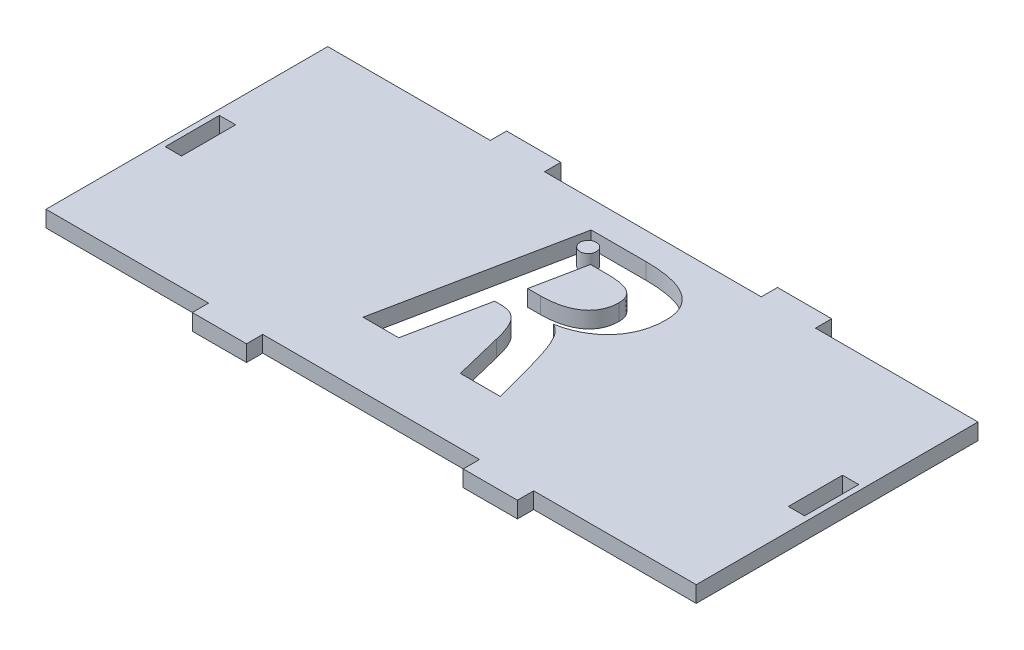
from build123d import *

# Parameters (mm, degrees)
SKETCH1_W             = 10
SKETCH1_H             = 3
BOSS_EXTRUDE1_DEPTH   = 3
BODY_MOVE_COPY1_ANGLE = 90
CUT_EXTRUDE1_DEPTH    = 10
SKETCH5_R             = 1.5
BOSS_EXTRUDE2_DEPTH   = 3


with BuildPart() as part:
    # Sketch1 → Boss-Extrude1 (new body)
    with BuildSketch(Plane(origin=(0, 0, 0), x_dir=(1, 0, 0), z_dir=(0, 1, 0))):
        Polygon((-26, 60), (26, 60), (26, 30), (29, 30), (29, 20), (26, 20), (26, -20), (29, -20), (29, -30), (26, -30), (26, -60), (-26, -60), (-26, -30), (-29, -30), (-29, -20), (-26, -20), (-26, 20), (-29, 20), (-29, 30), (-26, 30), align=None)
        with Locations((0, 57.5)):
            Rectangle(SKETCH1_W, SKETCH1_H, mode=Mode.SUBTRACT)
        with Locations((0, -57.5)):
            Rectangle(SKETCH1_W, SKETCH1_H, mode=Mode.SUBTRACT)
    extrude(amount=BOSS_EXTRUDE1_DEPTH)


with BuildPart() as part_1:
    # Body-Move/Copy1: moved
    add(part.part.rotate(Axis((2.335824912, 0, 2.335824912), (0, 1, 0)), BODY_MOVE_COPY1_ANGLE))

    # Sketch3 → Cut-Extrude1 (cut)
    with BuildSketch(Plane(origin=(0, 3, 0), x_dir=(1, 0, 0), z_dir=(0, 1, 0))):
        with BuildLine():
            Line((4.466938406, -18.671649823), (2.30321558, -9.810689678))
            add(Edge.make_bspline(
                [(2.30321558, -9.810689678), (2.237575072, -9.527203361), (2.112322927, -8.986268034), (1.884560825, -8.221822452), (1.661058011, -7.531047935), (1.413133081, -6.918626032), (1.157295895, -6.373259853), (0.894743907, -5.8869704), (0.595714484, -5.47180495), (0.194869077, -5.00534387), (-0.35624983, -4.53279488), (-1.130467052, -4.171954214), (-1.987113549, -3.997311886), (-2.583582774, -3.973814602), (-2.896059783, -3.961504895)],
                knots=[0, 0, 0, 0, 0.00087273, 0.001665302, 0.002392139, 0.003050022, 0.003645666, 0.004199163, 0.004704983, 0.005176946, 0.006043573, 0.006858998, 0.007710931, 0.008648313, 0.008648313, 0.008648313, 0.008648313], degree=3))
            Line((-2.896059783, -3.961504895), (-3.918478261, -3.961504895))
            Line((-3.918478261, -3.961504895), (-6.914402174, -18.671649823))
            Line((-6.914402174, -18.671649823), (-13.492753623, -18.671649823))
            Line((-13.492753623, -18.671649823), (-6.391304348, 16.328350177))
            Line((-6.391304348, 16.328350177), (3.769474638, 16.328350177))
            add(Edge.make_bspline(
                [(3.769474638, 16.328350177), (4.179114658, 16.324666316), (4.983349625, 16.317433894), (6.157480568, 16.235094411), (7.276899975, 16.110679294), (8.333759624, 15.931675368), (9.326691627, 15.693744473), (10.253459532, 15.406039359), (11.100069006, 15.038863675), (11.876823255, 14.621025917), (12.570210089, 14.133703622), (13.189907339, 13.589154481), (13.705367007, 12.959487705), (14.149571746, 12.275556031), (14.492611839, 11.511094404), (14.736787252, 10.668501563), (14.889995303, 9.747634617), (14.905202054, 9.105997443), (14.913043478, 8.775134597)],
                knots=[0, 0, 0, 0, 0.001228717, 0.002412307, 0.003529131, 0.004606709, 0.005625558, 0.006590578, 0.007513678, 0.008389749, 0.009231892, 0.010051352, 0.010856077, 0.011665161, 0.012491643, 0.013359356, 0.014290991, 0.015282848, 0.015282848, 0.015282848, 0.015282848], degree=3))
            add(Edge.make_bspline(
                [(14.913043478, 8.775134597), (14.90634048, 8.431261664), (14.893093398, 7.751668308), (14.760533036, 6.752319412), (14.555714135, 5.783564983), (14.26379236, 4.851946617), (13.888546868, 3.962405889), (13.443769752, 3.112441971), (12.911937837, 2.31580861), (12.30828054, 1.56624831), (11.631026441, 0.880423971), (10.901354362, 0.237517458), (10.094211296, -0.329736345), (9.23357218, -0.847429864), (8.305914573, -1.290927772), (7.327068955, -1.672081546), (6.288772428, -1.973702446), (5.57504277, -2.119764224), (5.211956522, -2.194068301)],
                knots=[0, 0, 0, 0, 0.001031106, 0.002037767, 0.003018669, 0.003998803, 0.004961477, 0.005911638, 0.006872255, 0.007830317, 0.008794328, 0.009760616, 0.010743694, 0.011749543, 0.012770455, 0.013824308, 0.014897768, 0.016009321, 0.016009321, 0.016009321, 0.016009321], degree=3))
            add(Edge.make_bspline(
                [(5.211956522, -2.194068301), (5.433677531, -2.329804407), (5.880826084, -2.603545735), (6.475860944, -3.157094687), (7.036852477, -3.827260458), (7.537100256, -4.668039178), (8.024074361, -5.674016505), (8.492355162, -6.873119692), (8.982550395, -8.283837505), (9.282680049, -9.30719032), (9.444293478, -9.858244026)],
                knots=[0, 0, 0, 0, 0.000778175, 0.00156936, 0.002424824, 0.003392672, 0.00449506, 0.0057755, 0.007251835, 0.008974345, 0.008974345, 0.008974345, 0.008974345], degree=3))
            Line((9.444293478, -9.858244026), (11.869565217, -18.671649823))
            Line((11.869565217, -18.671649823), (4.466938406, -18.671649823))
        make_face()
        with BuildLine():
            add(Edge.make_bspline(
                [(-0.534193841, 1.110958873), (-0.222271666, 1.114684086), (0.389426144, 1.12198945), (1.281419848, 1.203583832), (2.128065934, 1.33111856), (2.927947458, 1.499014183), (3.671997626, 1.734316476), (4.367486912, 1.995689795), (4.994203786, 2.327367466), (5.569374986, 2.688845671), (6.084812921, 3.102569872), (6.522516374, 3.575867415), (6.924121554, 4.074680151), (7.236379669, 4.635434575), (7.492492322, 5.235319597), (7.687442147, 5.876972177), (7.785143439, 6.566165217), (7.80264105, 7.036508201), (7.811594203, 7.277172641)],
                knots=[0, 0, 0, 0, 0.000935538, 0.001834645, 0.002684288, 0.003503557, 0.004283224, 0.005023548, 0.005728982, 0.006406156, 0.007059728, 0.007704446, 0.008337016, 0.008976008, 0.009622283, 0.010291854, 0.01098121, 0.011703539, 0.011703539, 0.011703539, 0.011703539], degree=3))
            add(Edge.make_bspline(
                [(7.811594203, 7.277172641), (7.798872985, 7.559208481), (7.774665424, 8.095902346), (7.523719172, 8.842936343), (7.094837748, 9.463606351), (6.487583788, 9.952170757), (5.703546602, 10.314133032), (4.741260196, 10.580707514), (3.583042546, 10.716731558), (2.749991851, 10.737501066), (2.30321558, 10.748640032)],
                knots=[0, 0, 0, 0, 0.000843857, 0.001605799, 0.002329127, 0.003078056, 0.003914624, 0.004903149, 0.006062203, 0.007402799, 0.007402799, 0.007402799, 0.007402799], degree=3))
            Line((2.30321558, 10.748640032), (-0.930480072, 10.748640032))
            Line((-0.930480072, 10.748640032), (-2.888134058, 1.110958873))
            Line((-2.888134058, 1.110958873), (-0.534193841, 1.110958873))
        make_face(mode=Mode.SUBTRACT)
    extrude(amount=-CUT_EXTRUDE1_DEPTH, mode=Mode.SUBTRACT)


with BuildPart() as body_2:
    # Sketch5 → Boss-Extrude2 (new body)
    with BuildSketch(Plane(origin=(0, 3, 0), x_dir=(1, 0, 0), z_dir=(0, 1, 0))):
        with Locations((-3.938871058, 13.328350177)):
            Circle(SKETCH5_R)
    extrude(amount=-BOSS_EXTRUDE2_DEPTH)


solid = Compound([part_1.part, body_2.part])
